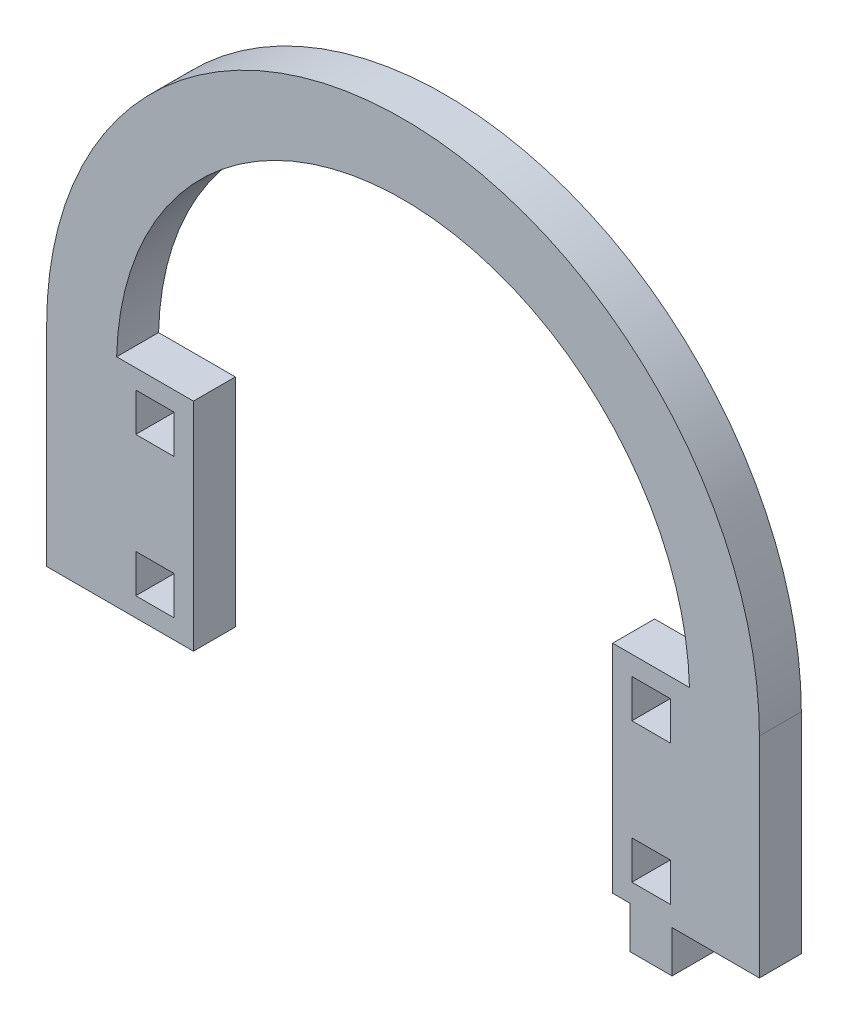
from build123d import *

# Parameters (mm, degrees)
MODEL_W             = 5.5
MODEL_H             = 5.5
BOSS_EXTRUDE1_DEPTH = 6


with BuildPart() as part:
    # Model → Boss-Extrude1 (new body)
    with BuildSketch(Plane.XY):
        with BuildLine():
            Line((3257.613450603, 1322.35524102), (3257.613450603, 1292.35524102))
            Line((3257.613450603, 1292.35524102), (3267.613450603, 1292.35524102))
            Line((3267.613450603, 1292.35524102), (3278.613450603, 1292.35524102))
            Line((3278.613450603, 1292.35524102), (3278.613450603, 1323.35524102))
            Line((3278.613450603, 1323.35524102), (3267.625647539, 1323.35524102))
            ThreePointArc((3267.625647539, 1323.35524102), (3308.613450603, 1363.35524102), (3349.601253667, 1323.35524102))
            Line((3349.601253667, 1323.35524102), (3338.613450603, 1323.35524102))
            Line((3338.613450603, 1323.35524102), (3338.613450603, 1292.35524102))
            Line((3338.613450603, 1292.35524102), (3341.113450603, 1292.35524102))
            Line((3341.113450603, 1292.35524102), (3341.113450603, 1286.35524102))
            Line((3341.113450603, 1286.35524102), (3347.113450603, 1286.35524102))
            Line((3347.113450603, 1286.35524102), (3347.113450603, 1292.35524102))
            Line((3347.113450603, 1292.35524102), (3359.613450603, 1292.35524102))
            Line((3359.613450603, 1292.35524102), (3359.613450603, 1322.35524102))
            ThreePointArc((3359.613450603, 1322.35524102), (3308.613450603, 1373.35524102), (3257.613450603, 1322.35524102))
        make_face()
        with Locations((3344.113450603, 1297.85524102)):
            Rectangle(MODEL_W, MODEL_H, mode=Mode.SUBTRACT)
        with Locations((3344.113450603, 1317.85524102)):
            Rectangle(MODEL_W, MODEL_H, mode=Mode.SUBTRACT)
        with Locations((3273.113450603, 1297.85524102)):
            Rectangle(MODEL_W, MODEL_H, mode=Mode.SUBTRACT)
        with Locations((3273.113450603, 1317.85524102)):
            Rectangle(MODEL_W, MODEL_H, mode=Mode.SUBTRACT)
    extrude(amount=BOSS_EXTRUDE1_DEPTH)


solid = part.part
